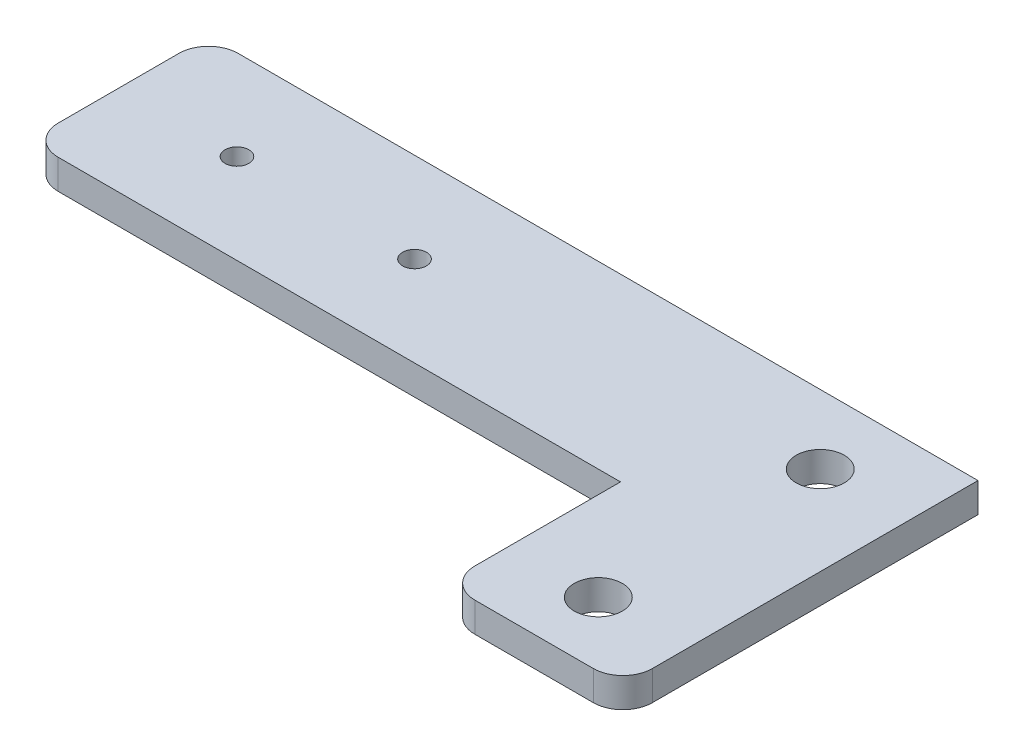
from build123d import *

# Parameters (mm, degrees)
BOSS_EXTRUDE1_DEPTH = 6.35
CUT_EXTRUDE1_REACH  = 8.35
SKETCH4_R           = 2.5527
SKETCH4_R_2         = 5.1562
FILLET1_R           = 6.35


with BuildPart() as part:
    # Sketch3 → Boss-Extrude1 (new body)
    with BuildSketch(Plane(origin=(0, 0, 0), x_dir=(1, 0, 0), z_dir=(0, 1, 0))):
        Polygon((0, 0), (165.1, 0), (165.1, -76.2), (127, -76.2), (127, -38.608), (0, -38.608), align=None)
    extrude(amount=BOSS_EXTRUDE1_DEPTH)

    # Sketch4 → Cut-Extrude1 (cut, up to next)
    with BuildSketch(Plane(origin=(0, 6.35, 0), x_dir=(1, 0, 0), z_dir=(0, 1, 0)), mode=Mode.PRIVATE) as cut_extrude1_sk1:
        with Locations((25.4, -19.304)):
            Circle(SKETCH4_R)
    cut_extrude1_tool1 = extrude(cut_extrude1_sk1.sketch, amount=-CUT_EXTRUDE1_REACH, mode=Mode.PRIVATE) & part.part
    add(cut_extrude1_tool1.solids().sort_by_distance((25.4, 6.35, 19.304))[0], mode=Mode.SUBTRACT)
    # Sketch4 → Cut-Extrude1 (cut, up to next)
    with BuildSketch(Plane(origin=(0, 6.35, 0), x_dir=(1, 0, 0), z_dir=(0, 1, 0)), mode=Mode.PRIVATE) as cut_extrude1_sk2:
        with Locations((63.5, -19.304)):
            Circle(SKETCH4_R)
    cut_extrude1_tool2 = extrude(cut_extrude1_sk2.sketch, amount=-CUT_EXTRUDE1_REACH, mode=Mode.PRIVATE) & part.part
    add(cut_extrude1_tool2.solids().sort_by_distance((63.5, 6.35, 19.304))[0], mode=Mode.SUBTRACT)
    # Sketch4 → Cut-Extrude1 (cut, up to next)
    with BuildSketch(Plane(origin=(0, 6.35, 0), x_dir=(1, 0, 0), z_dir=(0, 1, 0)), mode=Mode.PRIVATE) as cut_extrude1_sk3:
        with Locations((146.05, -14.7955)):
            Circle(SKETCH4_R_2)
    cut_extrude1_tool3 = extrude(cut_extrude1_sk3.sketch, amount=-CUT_EXTRUDE1_REACH, mode=Mode.PRIVATE) & part.part
    add(cut_extrude1_tool3.solids().sort_by_distance((146.05, 6.35, 14.7955))[0], mode=Mode.SUBTRACT)
    # Sketch4 → Cut-Extrude1 (cut, up to next)
    with BuildSketch(Plane(origin=(0, 6.35, 0), x_dir=(1, 0, 0), z_dir=(0, 1, 0)), mode=Mode.PRIVATE) as cut_extrude1_sk4:
        with Locations((146.05, -62.4205)):
            Circle(SKETCH4_R_2)
    cut_extrude1_tool4 = extrude(cut_extrude1_sk4.sketch, amount=-CUT_EXTRUDE1_REACH, mode=Mode.PRIVATE) & part.part
    add(cut_extrude1_tool4.solids().sort_by_distance((146.05, 6.35, 62.4205))[0], mode=Mode.SUBTRACT)

    # Fillet1
    fillet1_edges = [part.edges().sort_by_distance(p)[0] for p in [
        (0, 3.175, 0),
        (165.1, 3.175, 76.2),
        (127, 3.175, 76.2),
        (0, 3.175, 38.608),
    ]]
    fillet(fillet1_edges, radius=FILLET1_R)


solid = part.part
